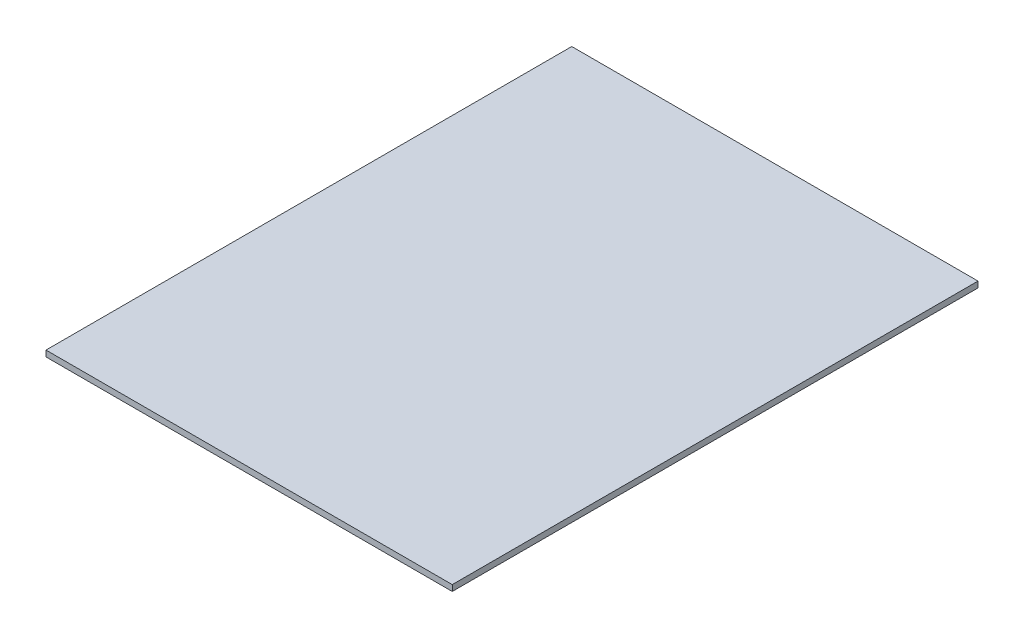
from build123d import *

# Parameters (mm, degrees)
SKETCH1_W           = 215.9
SKETCH1_H           = 279.4
BOSS_EXTRUDE1_DEPTH = 3.175


with BuildPart() as part:
    # Sketch1 → Boss-Extrude1 (new body)
    with BuildSketch(Plane(origin=(0, 0, 0), x_dir=(1, 0, 0), z_dir=(0, 1, 0))):
        with Locations((107.95, 139.7)):
            Rectangle(SKETCH1_W, SKETCH1_H)
    extrude(amount=BOSS_EXTRUDE1_DEPTH)


solid = part.part
